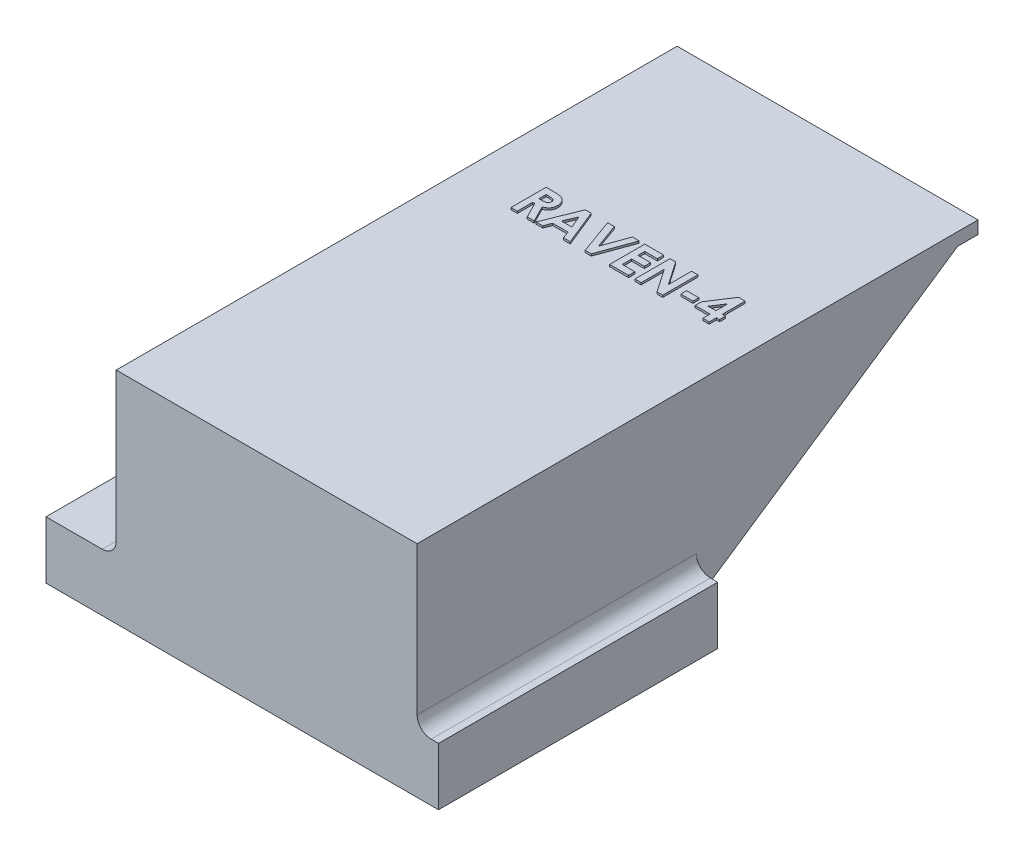
from build123d import *

# Parameters (mm, degrees)
SKETCH1_W            = 29.979
SKETCH1_H            = 55.89
BOSS_EXTRUDE1_DEPTH  = 21.895
SHELL1_T             = -1.27
CUT_EXTRUDE1_DEPTH   = 30.979
SKETCH48_W           = 1.211538461
SKETCH48_H           = 0.583333333
BOSS_EXTRUDE9_DEPTH  = 0.2
SKETCH44_W           = 27.823
SKETCH44_H           = 5.731
BOSS_EXTRUDE10_DEPTH = 2.133
FILLET1_R            = 1.4
SKETCH49_W           = 27.823
SKETCH49_H           = 5.731
BOSS_EXTRUDE11_DEPTH = 7
FILLET2_R            = 1.4


with BuildPart() as part:
    # Sketch1 → Boss-Extrude1 (new body)
    with BuildSketch(Plane(origin=(0, 0, 0), x_dir=(1, 0, 0), z_dir=(0, 1, 0))):
        Rectangle(SKETCH1_W, SKETCH1_H)
    extrude(amount=BOSS_EXTRUDE1_DEPTH)

    # Shell1
    shell1_openings = [part.faces().sort_by_distance(p)[0] for p in [
        (0, 0, 0),
        (0, 10.9475, -27.945),
    ]]
    offset(amount=SHELL1_T, openings=shell1_openings, kind=Kind.INTERSECTION)

    # Sketch2 → Cut-Extrude1 (cut, through all)
    with BuildSketch(Plane(origin=(14.9895, 0, 0), x_dir=(0, 0, -1), z_dir=(1, 0, 0))):
        Polygon((-127.812023791, 0), (-0.122, 0), (27.945, 0), (27.945, 20.625), (25.908, 20.625), (-0.122, 3.048), (-26.675, 3.048), (-26.675, 0), (-26.675, -127.690023791), (173.517200789, 30.872429036), (72.380176997, 158.562452828), align=None)
    extrude(amount=-CUT_EXTRUDE1_DEPTH, mode=Mode.SUBTRACT)

    # Sketch48 → Boss-Extrude9 (add)
    with BuildSketch(Plane(origin=(0, 21.895, 0), x_dir=(1, 0, 0), z_dir=(0, 1, 0))):
        with BuildLine():
            Line((-9.146792076, 9.049695188), (-8.414820922, 9.049695188))
            add(Edge.make_bspline(
                [(-8.414820922, 9.049695188), (-8.366437852, 9.049523455), (-8.273383578, 9.049193166), (-8.139204399, 9.043982076), (-8.01594237, 9.036730417), (-7.903414991, 9.025664193), (-7.801670402, 9.010991718), (-7.710606633, 8.993695297), (-7.630226345, 8.973982317), (-7.559851641, 8.949418389), (-7.49634195, 8.921710651), (-7.437142089, 8.889873951), (-7.380946021, 8.854262803), (-7.328129354, 8.813940179), (-7.278233101, 8.769631474), (-7.231163129, 8.721292087), (-7.187584581, 8.668512119), (-7.147767295, 8.611625075), (-7.111477045, 8.551781208), (-7.079404075, 8.488898353), (-7.053322282, 8.42293278), (-7.030276223, 8.354837833), (-7.013676892, 8.283640082), (-7.002132301, 8.210032649), (-6.993679803, 8.133756428), (-6.993193825, 8.08193775), (-6.992945922, 8.055504482)],
                knots=[0, 0, 0, 0, 0.000145139, 0.000279143, 0.000402781, 0.00051552, 0.000618244, 0.00071106, 0.000793533, 0.000866261, 0.000934389, 0.001001202, 0.00106772, 0.001133767, 0.001200318, 0.00126775, 0.001335975, 0.001405418, 0.00147588, 0.001545802, 0.001616889, 0.001688503, 0.001761288, 0.001835865, 0.001911978, 0.001991232, 0.001991232, 0.001991232, 0.001991232], degree=3))
            add(Edge.make_bspline(
                [(-6.992945922, 8.055504482), (-6.993589884, 8.027914224), (-6.994852577, 7.973814755), (-7.001654125, 7.894347048), (-7.014085219, 7.818317905), (-7.03291392, 7.745949929), (-7.054555066, 7.676342416), (-7.083332238, 7.61077967), (-7.115810122, 7.548308174), (-7.154383155, 7.489811611), (-7.196715174, 7.433990657), (-7.245946422, 7.382984018), (-7.298887471, 7.334050282), (-7.358514328, 7.290254491), (-7.422198587, 7.248635332), (-7.491205588, 7.210917291), (-7.565084966, 7.176152222), (-7.617025828, 7.156764818), (-7.643586948, 7.146850636)],
                knots=[0, 0, 0, 0, 8.278e-05, 0.000162316, 0.000239082, 0.000313563, 0.00038651, 0.000457489, 0.000528056, 0.000597481, 0.00066746, 0.000737887, 0.000809857, 0.000883475, 0.000959513, 0.001037964, 0.001119203, 0.001204224, 0.001204224, 0.001204224, 0.001204224], degree=3))
            Line((-7.643586948, 7.146850636), (-6.83589464, 5.549695188))
            Line((-6.83589464, 5.549695188), (-7.534211948, 5.549695188))
            Line((-7.534211948, 5.549695188), (-8.305445922, 7.075336213))
            Line((-8.305445922, 7.075336213), (-8.518586948, 7.075336213))
            Line((-8.518586948, 7.075336213), (-8.518586948, 5.549695188))
            Line((-8.518586948, 5.549695188), (-9.146792076, 5.549695188))
            Line((-9.146792076, 5.549695188), (-9.146792076, 9.049695188))
        make_face()
        with BuildLine():
            Line((-8.518586948, 7.703541341), (-8.273895441, 7.703541341))
            add(Edge.make_bspline(
                [(-8.273895441, 7.703541341), (-8.243979871, 7.703878271), (-8.186697981, 7.704523418), (-8.1043191, 7.707515878), (-8.02949943, 7.714726227), (-7.961917669, 7.723836234), (-7.901233753, 7.734355053), (-7.847988961, 7.74942916), (-7.801362872, 7.765581446), (-7.761908006, 7.785654548), (-7.728198675, 7.808482019), (-7.699092825, 7.834414593), (-7.675018114, 7.864428245), (-7.655203399, 7.897707335), (-7.639789705, 7.934546206), (-7.628538889, 7.974540452), (-7.622251347, 8.018145659), (-7.621527944, 8.04823919), (-7.62115105, 8.063917944)],
                knots=[0, 0, 0, 0, 8.9755e-05, 0.000171861, 0.000247208, 0.00031513, 0.000376461, 0.000431743, 0.000480981, 0.000524253, 0.000564118, 0.000602839, 0.000640725, 0.000679082, 0.000718669, 0.000760178, 0.000803409, 0.000850432, 0.000850432, 0.000850432, 0.000850432], degree=3))
            add(Edge.make_bspline(
                [(-7.62115105, 8.063917944), (-7.621863602, 8.082467055), (-7.623263279, 8.118903347), (-7.637152416, 8.17135883), (-7.659260923, 8.219909969), (-7.68956563, 8.264337397), (-7.727730469, 8.303285548), (-7.771527633, 8.337618653), (-7.82190237, 8.364766703), (-7.868545586, 8.382673268), (-7.91098001, 8.393386951), (-7.949275739, 8.401370692), (-7.993622423, 8.407028999), (-8.044053543, 8.413030641), (-8.100440547, 8.416922401), (-8.163090778, 8.419762611), (-8.231824306, 8.42092468), (-8.279738103, 8.421296173), (-8.3047448, 8.421490059)],
                knots=[0, 0, 0, 0, 5.5548e-05, 0.000109114, 0.000161511, 0.00021499, 0.000269533, 0.000324507, 0.000381303, 0.00044055, 0.000473881, 0.00051252, 0.000557833, 0.000607927, 0.000664874, 0.000727337, 0.000796061, 0.000871084, 0.000871084, 0.000871084, 0.000871084], degree=3))
            Line((-8.3047448, 8.421490059), (-8.518586948, 8.421490059))
            Line((-8.518586948, 8.421490059), (-8.518586948, 7.703541341))
        make_face(mode=Mode.SUBTRACT)
        Polygon((-5.2422448, 9.049695188), (-4.659612589, 9.049695188), (-3.24615105, 5.549695188), (-3.917124608, 5.549695188), (-4.189159864, 6.267643906), (-5.714099768, 6.267643906), (-5.986135025, 5.549695188), (-6.656407461, 5.549695188), align=None)
        Polygon((-4.951279255, 8.110893104), (-5.475718358, 6.895849034), (-4.426840153, 6.895849034), align=None, mode=Mode.SUBTRACT)
        Polygon((-3.021792076, 9.049695188), (-2.350818518, 9.049695188), (-1.451279255, 6.563517303), (-0.549636627, 9.049695188), (0.119233565, 9.049695188), (-1.149796884, 5.549695188), (-1.754864993, 5.549695188), align=None)
        Polygon((0.680131001, 9.049695188), (2.564746386, 9.049695188), (2.564746386, 8.421490059), (1.308336129, 8.421490059), (1.308336129, 7.748413136), (2.564746386, 7.748413136), (2.564746386, 7.120208008), (1.308336129, 7.120208008), (1.308336129, 6.177900316), (2.564746386, 6.177900316), (2.564746386, 5.549695188), (0.680131001, 5.549695188), align=None)
        Polygon((3.192951514, 9.049695188), (3.758756802, 9.049695188), (5.346797668, 6.746510091), (5.346797668, 9.049695188), (5.975002796, 9.049695188), (5.975002796, 5.549695188), (5.404990777, 5.549695188), (3.821156642, 7.845869066), (3.821156642, 5.549695188), (3.192951514, 5.549695188), align=None)
        with Locations((7.388464335, 6.828541342)):
            Rectangle(SKETCH48_W, SKETCH48_H)
        Polygon((9.941949911, 9.139438777), (10.596797668, 9.139438777), (10.596797668, 6.850977239), (10.910900232, 6.850977239), (10.910900232, 6.267643906), (10.596797668, 6.267643906), (10.596797668, 5.549695188), (9.968592539, 5.549695188), (9.968592539, 6.267643906), (8.487823309, 6.267643906), (8.487823309, 6.903561373), align=None)
        Polygon((9.968592539, 6.850977239), (9.968592539, 8.042183168), (9.193852956, 6.850977239), align=None, mode=Mode.SUBTRACT)
    extrude(amount=BOSS_EXTRUDE9_DEPTH)

    # Sketch44 → Boss-Extrude10 (add)
    with BuildSketch(Plane(origin=(14.9895, 0, 0), x_dir=(0, 0, -1), z_dir=(1, 0, 0))):
        with Locations((-14.0335, 2.8655)):
            Rectangle(SKETCH44_W, SKETCH44_H)
    extrude(amount=BOSS_EXTRUDE10_DEPTH)

    # Fillet1
    fillet1_edges = [part.edges().sort_by_distance(p)[0] for p in [
        (14.9895, 5.731, 14.0335),
    ]]
    fillet(fillet1_edges, radius=FILLET1_R)

    # Sketch49 → Boss-Extrude11 (add)
    with BuildSketch(Plane.ZY.offset(14.9895)):
        with Locations((14.0335, 2.8655)):
            Rectangle(SKETCH49_W, SKETCH49_H)
    extrude(amount=BOSS_EXTRUDE11_DEPTH)

    # Fillet2
    fillet2_edges = [part.edges().sort_by_distance(p)[0] for p in [
        (-14.9895, 5.731, 14.0335),
    ]]
    fillet(fillet2_edges, radius=FILLET2_R)


solid = part.part
